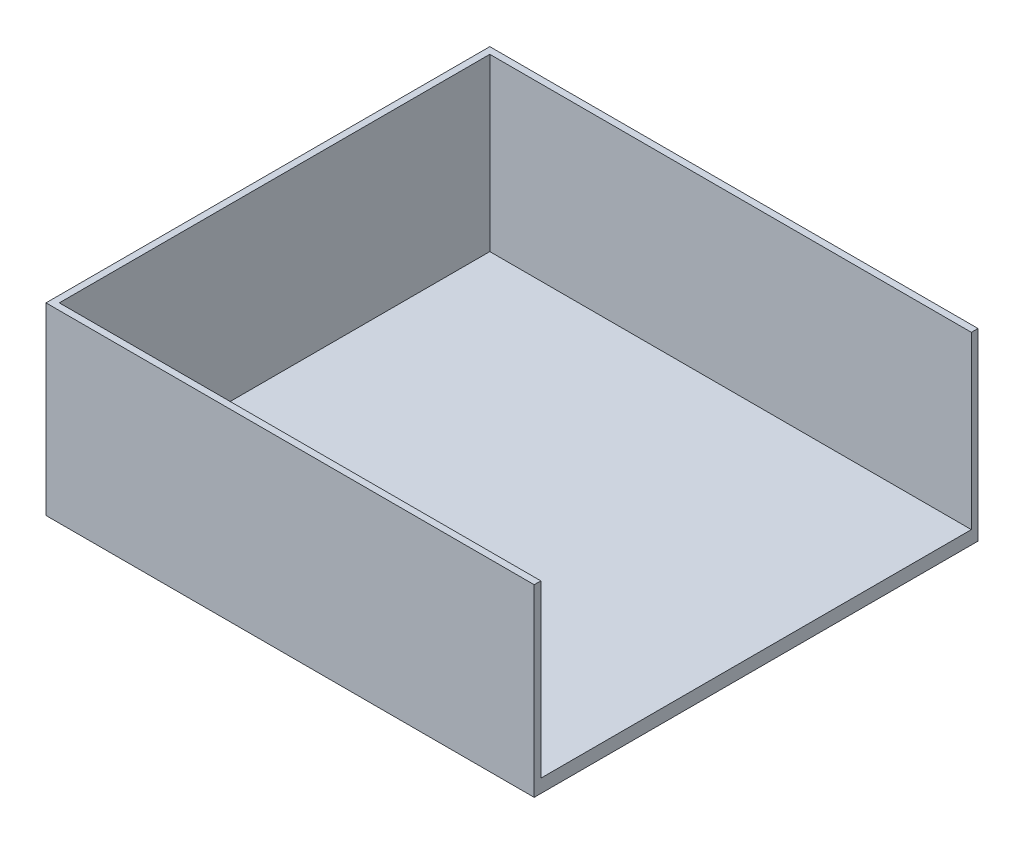
from build123d import *

# Parameters (mm, degrees)
SKETCH1_W           = 220
SKETCH1_H           = 200
BOSS_EXTRUDE1_DEPTH = 3
SKETCH3_W           = 220
SKETCH3_H           = 200
BOSS_EXTRUDE3_DEPTH = 80
SKETCH9_W           = 214
SKETCH9_H           = 194
CUT_EXTRUDE1_DEPTH  = 77
SKETCH13_W          = 194
SKETCH13_H          = 77
CUT_EXTRUDE4_DEPTH  = 197


with BuildPart() as part:
    # Sketch1 → Boss-Extrude1 (new body)
    with BuildSketch(Plane(origin=(0, 0, 0), x_dir=(1, 0, 0), z_dir=(0, 1, 0))):
        with Locations((2.493847253, -12.542456993)):
            Rectangle(SKETCH1_W, SKETCH1_H)
    extrude(amount=BOSS_EXTRUDE1_DEPTH)

    # Sketch3 → Boss-Extrude3 (add)
    with BuildSketch(Plane(origin=(0, 3, 0), x_dir=(1, 0, 0), z_dir=(0, 1, 0))):
        with Locations((2.493847253, -12.542456993)):
            Rectangle(SKETCH3_W, SKETCH3_H)
    extrude(amount=BOSS_EXTRUDE3_DEPTH)

    # Sketch9 → Cut-Extrude1 (cut)
    with BuildSketch(Plane(origin=(0, 83, 0), x_dir=(1, 0, 0), z_dir=(0, 1, 0))):
        with Locations((2.493847253, -12.542456993)):
            Rectangle(SKETCH9_W, SKETCH9_H)
    extrude(amount=-CUT_EXTRUDE1_DEPTH, mode=Mode.SUBTRACT)

    # Sketch13 → Cut-Extrude4 (cut)
    with BuildSketch(Plane.ZY.offset(-109.493847253)):
        with Locations((12.542456993, 44.5)):
            Rectangle(SKETCH13_W, SKETCH13_H)
    extrude(amount=-CUT_EXTRUDE4_DEPTH, mode=Mode.SUBTRACT)


solid = part.part
